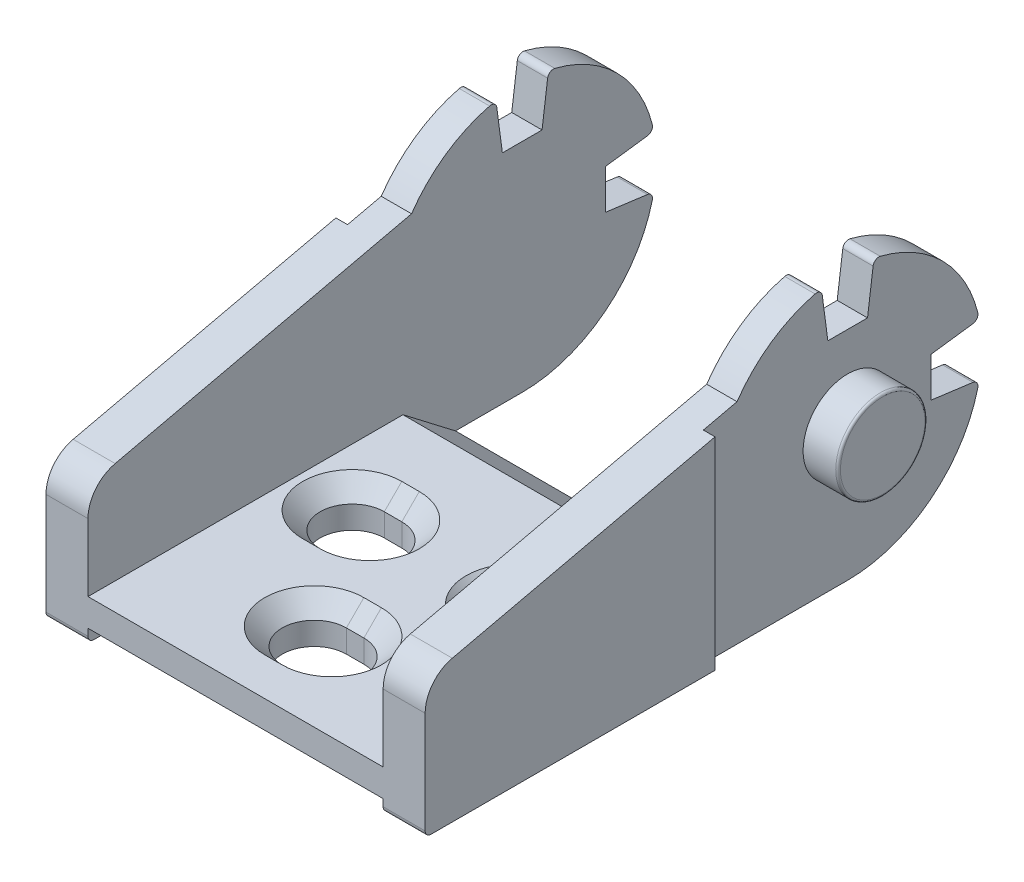
from build123d import *

# Parameters (mm, degrees)
BOSS_EXTRUDE1_DEPTH = 16.25
CUT_EXTRUDE1_DEPTH  = 1
SKETCH3_R           = 3.825
BOSS_EXTRUDE2_DEPTH = 3
CUT_EXTRUDE2_DEPTH  = 25.3
FILLET1_R           = 0.2
FILLET2_R           = 0.5
FILLET3_R           = 3
CUT_EXTRUDE3_DEPTH  = 4.45
CHAMFER1_SIZE       = 1.5


with BuildPart() as part:
    # Sketch1 → Boss-Extrude1 (new body, symmetric)
    with BuildSketch(Plane(origin=(0, 0, 0), x_dir=(0, 0, -1), z_dir=(1, 0, 0))):
        with BuildLine():
            Line((0, 0), (37.222256431, 0))
            ThreePointArc((37.222256431, 0), (44.515232504, 2.608290378), (48.5, 9.25))
            Line((48.5, 9.25), (44.35, 9.8))
            Line((44.35, 9.8), (44.35, 13.2))
            Line((44.35, 13.2), (48.5, 13.75))
            ThreePointArc((48.5, 13.75), (45.353984415, 19.631727984), (39.472256431, 22.777743569))
            Line((39.472256431, 22.777743569), (38.922256431, 18.627743569))
            Line((38.922256431, 18.627743569), (35.522256431, 18.627743569))
            Line((35.522256431, 18.627743569), (34.972256431, 22.777743569))
            ThreePointArc((34.972256431, 22.777743569), (30.886246606, 21.097133921), (27.735423451, 18))
            Line((27.735423451, 18), (0, 11.626817203))
            Line((0, 11.626817203), (0, 0))
        make_face()
    extrude(amount=BOSS_EXTRUDE1_DEPTH, both=True)

    # Sketch2 → Cut-Extrude1 (cut)
    with BuildSketch(Plane(origin=(16.25, 0, 0), x_dir=(0, 0, -1), z_dir=(1, 0, 0))):
        Polygon((24.85, 17.336973126), (24.85, 0), (48.5, 0), (48.5, 22.777743569), (24.85, 22.777743569), align=None)
    cut_extrude1 = extrude(amount=-CUT_EXTRUDE1_DEPTH, mode=Mode.SUBTRACT)

    # Sketch3 → Boss-Extrude2 (add)
    with BuildSketch(Plane(origin=(15.25, 0, 0), x_dir=(0, 0, -1), z_dir=(1, 0, 0))):
        with Locations((37.222256431, 11.5)):
            Circle(SKETCH3_R)
    boss_extrude2 = extrude(amount=BOSS_EXTRUDE2_DEPTH)

    # Mirror1: Cut-Extrude1, Boss-Extrude2 across plane
    add(cut_extrude1.mirror(Plane(origin=(0, 0, 0), x_dir=(0, 0, 1), z_dir=(1, 0, 0))), mode=Mode.SUBTRACT)
    add(boss_extrude2.mirror(Plane(origin=(0, 0, 0), x_dir=(0, 0, 1), z_dir=(1, 0, 0))))

    # Sketch4 → Cut-Extrude2 (cut)
    with BuildSketch(Plane(origin=(12.65, 0, 0), x_dir=(0, 0, -1), z_dir=(1, 0, 0))):
        Polygon((0, 1.1), (1.35, 1.1), (1.35, 2.7), (2.65, 2.7), (2.65, 0), (0, 0), align=None)
        Polygon((0, 3.45), (27, 3.45), (31.5, 0), (48.5, 0), (48.5, 22.777743569), (0, 22.777743569), align=None)
    extrude(amount=-CUT_EXTRUDE2_DEPTH, mode=Mode.SUBTRACT)

    # Fillet1
    fillet1_edges = [part.edges().sort_by_distance(p)[0] for p in [
        (-18.25, 11.5, -33.397256431),
        (18.25, 11.5, -33.397256431),
    ]]
    fillet(fillet1_edges, radius=FILLET1_R)

    # Fillet2
    fillet2_edges = [part.edges().sort_by_distance(p)[0] for p in [
        (-14.45, 0, 0),
        (-13.95, 22.777743569, -34.972256431),
        (-13.95, 22.777743569, -39.472256431),
        (-13.95, 13.75, -48.5),
        (-13.95, 9.25, -48.5),
        (14.45, 0, 0),
        (13.95, 22.777743569, -34.972256431),
        (13.95, 22.777743569, -39.472256431),
        (13.95, 13.75, -48.5),
        (13.95, 9.25, -48.5),
    ]]
    fillet(fillet2_edges, radius=FILLET2_R)

    # Fillet3
    fillet3_edges = [part.edges().sort_by_distance(p)[0] for p in [
        (-14.45, 11.626817203, 0),
        (14.45, 11.626817203, 0),
    ]]
    fillet(fillet3_edges, radius=FILLET3_R)

    # Sketch5 → Cut-Extrude3 (cut, through all)
    with BuildSketch(Plane(origin=(0, 3.45, 0), x_dir=(1, 0, 0), z_dir=(0, 1, 0))):
        with BuildLine():
            Line((-0.75, 4.75), (0.75, 4.75))
            ThreePointArc((0.75, 4.75), (3.5, 7.5), (0.75, 10.25))
            Line((0.75, 10.25), (-0.75, 10.25))
            ThreePointArc((-0.75, 10.25), (-3.5, 7.5), (-0.75, 4.75))
        make_face()
        with BuildLine():
            Line((7.75, 20.5), (6.25, 20.5))
            ThreePointArc((6.25, 20.5), (3.5, 17.75), (6.25, 15))
            Line((6.25, 15), (7.75, 15))
            ThreePointArc((7.75, 15), (10.5, 17.75), (7.75, 20.5))
        make_face()
        with BuildLine():
            Line((-7.75, 20.5), (-6.25, 20.5))
            ThreePointArc((-6.25, 20.5), (-3.5, 17.75), (-6.25, 15))
            Line((-6.25, 15), (-7.75, 15))
            ThreePointArc((-7.75, 15), (-10.5, 17.75), (-7.75, 20.5))
        make_face()
    extrude(amount=-CUT_EXTRUDE3_DEPTH, mode=Mode.SUBTRACT)

    # Chamfer1
    chamfer1_edges = [part.edges().sort_by_distance(p)[0] for p in [
        (-3.5, 3.45, -7.5),
        (0, 3.45, -4.75),
        (3.5, 3.45, -7.5),
        (0, 3.45, -10.25),
        (10.5, 3.45, -17.75),
        (7, 3.45, -20.5),
        (3.5, 3.45, -17.75),
        (7, 3.45, -15),
        (-10.5, 3.45, -17.75),
        (-7, 3.45, -15),
        (-3.5, 3.45, -17.75),
        (-7, 3.45, -20.5),
    ]]
    chamfer(chamfer1_edges, length=CHAMFER1_SIZE)


solid = part.part
